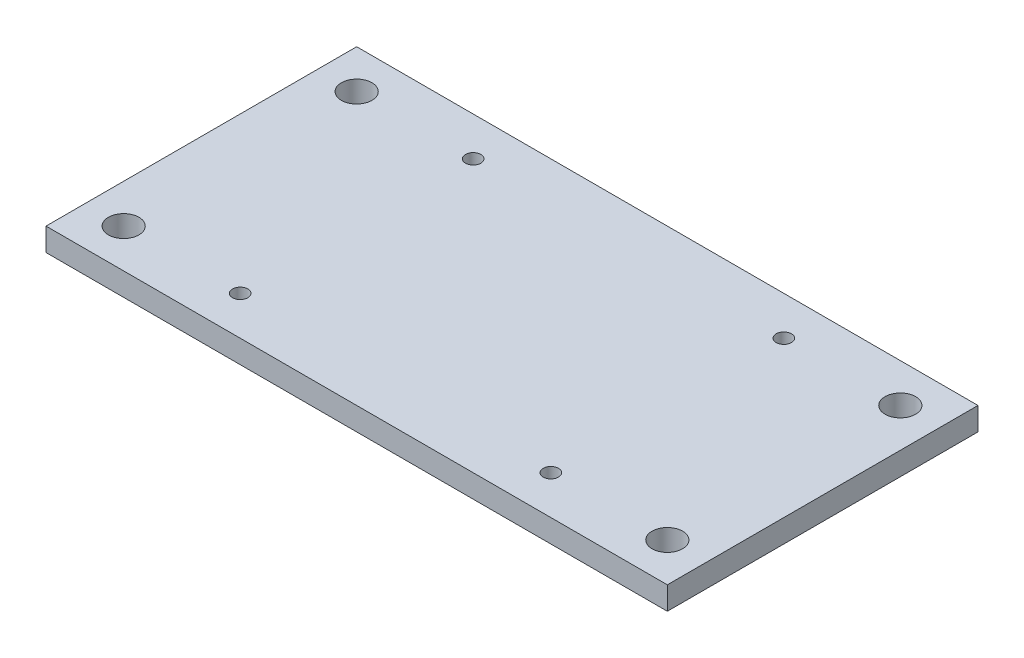
from build123d import *

# Parameters (mm, degrees)
SKETCH1_W           = 40.64
SKETCH1_H           = 20.32
SKETCH1_R           = 1
SKETCH1_R_2         = 0.5
BOSS_EXTRUDE1_DEPTH = 1.5


with BuildPart() as part:
    # Sketch1 → Boss-Extrude1 (new body)
    with BuildSketch(Plane(origin=(0, 0, 0), x_dir=(1, 0, 0), z_dir=(0, 1, 0))):
        with Locations((20.32, 10.16)):
            Rectangle(SKETCH1_W, SKETCH1_H)
        with Locations(Location((2.54, 2.54, 0), (0, 0, 270))):  # turned: the seam where the file's is
            Circle(SKETCH1_R, mode=Mode.SUBTRACT)
        with Locations(Location((38.1, 2.54, 0), (0, 0, 90))):  # turned: the seam where the file's is
            Circle(SKETCH1_R, mode=Mode.SUBTRACT)
        with Locations(Location((38.1, 17.78, 0), (0, 0, 270))):  # turned: the seam where the file's is
            Circle(SKETCH1_R, mode=Mode.SUBTRACT)
        with Locations(Location((2.54, 17.78, 0), (0, 0, 90))):  # turned: the seam where the file's is
            Circle(SKETCH1_R, mode=Mode.SUBTRACT)
        with Locations(Location((10.16, 2.54, 0), (0, 0, 270))):  # turned: the seam where the file's is
            Circle(SKETCH1_R_2, mode=Mode.SUBTRACT)
        with Locations(Location((10.16, 17.78, 0), (0, 0, 90))):  # turned: the seam where the file's is
            Circle(SKETCH1_R_2, mode=Mode.SUBTRACT)
        with Locations(Location((30.48, 2.54, 0), (0, 0, 90))):  # turned: the seam where the file's is
            Circle(SKETCH1_R_2, mode=Mode.SUBTRACT)
        with Locations(Location((30.48, 17.78, 0), (0, 0, 270))):  # turned: the seam where the file's is
            Circle(SKETCH1_R_2, mode=Mode.SUBTRACT)
    extrude(amount=BOSS_EXTRUDE1_DEPTH)


solid = part.part
